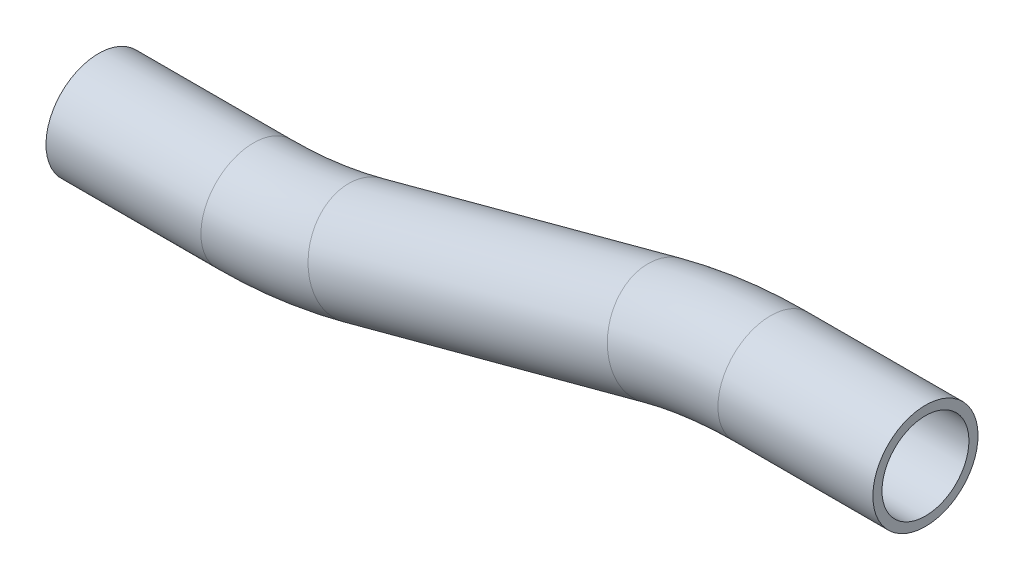
from build123d import *

# Parameters (mm, degrees)
SKETCH2_R   = 9.525
SKETCH2_R_2 = 7.874


with BuildPart() as part:
    # Sweep1: sweep along a path in Sketch1
    with BuildLine(Plane.XY) as sweep1_path:
        Line((28.068079684, 0), (0, 0))
        ThreePointArc((0, 0), (-9.946095847, -0.651901563), (-19.722011237, -2.596452037))
        Line((-19.722011237, -2.596452037), (-73.945377359, -17.1255592))
        ThreePointArc((-73.945377359, -17.1255592), (-83.721292748, -19.070109673), (-93.667388596, -19.722011237))
        Line((-93.667388596, -19.722011237), (-121.735468279, -19.722011237))
    # Sketch2 → Sweep1 (sweep)
    with BuildSketch(Plane.ZY.offset(-28.068079684)):
        Circle(SKETCH2_R)
        Circle(SKETCH2_R_2, mode=Mode.SUBTRACT)
    sweep(path=sweep1_path.line)


solid = part.part
